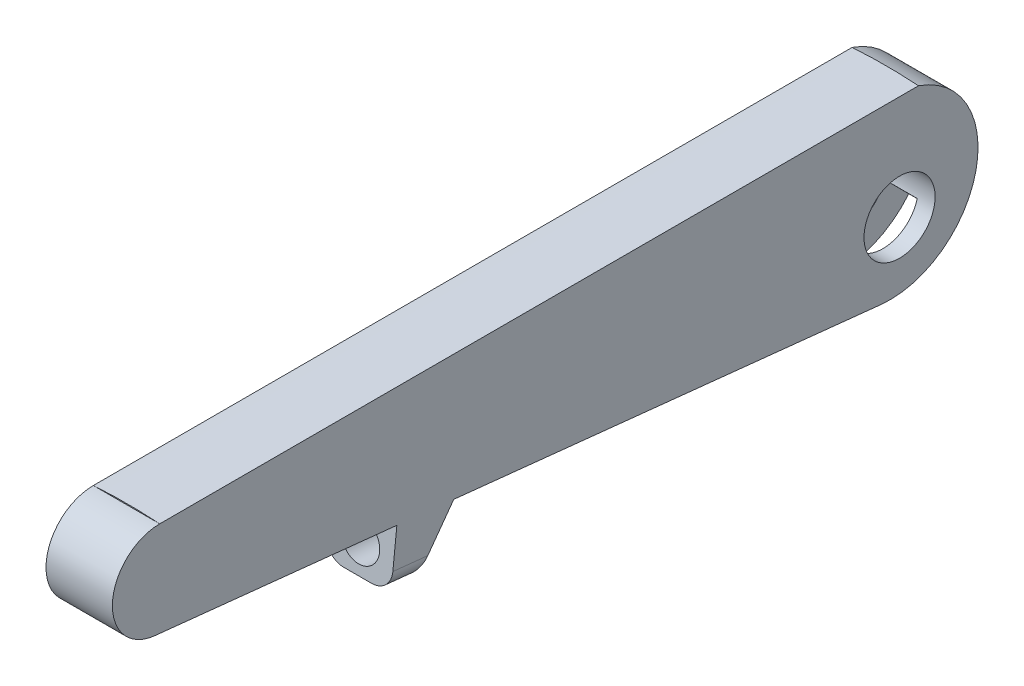
from build123d import *

# Parameters (mm, degrees)
SKETCH1_R           = 3.75
BOSS_EXTRUDE1_DEPTH = 3.5
CUT_EXTRUDE1_DEPTH  = 1.75
BOSS_EXTRUDE3_DEPTH = 80
SKETCH9_R           = 2
CUT_EXTRUDE3_DEPTH  = 7
FILLET2_R           = 2
BOSS_EXTRUDE7_DEPTH = 3.5


with BuildPart() as part:
    # Sketch1 → Boss-Extrude1 (new body, symmetric)
    with BuildSketch(Plane(origin=(0, 0, 0), x_dir=(0, 0, -1), z_dir=(1, 0, 0))):
        with BuildLine():
            Line((-80.521669114, -9.954039671), (-3.96947016, -18))
            ThreePointArc((-3.96947016, -18), (6.057083574, -10.773431066), (0, 0))
            Line((0, 0), (-80, 0))
            ThreePointArc((-80, 0), (-84.983850029, -4.729497083), (-80.521669114, -9.954039671))
        make_face()
        with Locations((-2, -11)):
            Circle(SKETCH1_R, mode=Mode.SUBTRACT)
        Polygon((-53.094727027, -18.903008846), (-49, -13.267100598), (-55, -12.636475186), (-55.630625412, -18.636475186), align=None)
    extrude(amount=BOSS_EXTRUDE1_DEPTH, both=True)

    # Sketch6 → Cut-Extrude1 (cut, symmetric)
    with BuildSketch(Plane(origin=(0, 0, 0), x_dir=(0, 0, -1), z_dir=(1, 0, 0))):
        with BuildLine():
            ThreePointArc((1.619477331, -11.980756773), (-4.659098946, -13.644180931), (-2.960378385, -7.375062296))
            Line((-2.960378385, -7.375062296), (-31.959880017, -15.058089377))
            Line((-31.959880017, -15.058089377), (-3.96947016, -18))
            ThreePointArc((-3.96947016, -18), (0.558835237, -17.340846662), (4.220806393, -14.596762087))
            Line((4.220806393, -14.596762087), (1.619477331, -11.980756773))
        make_face()
    extrude(amount=CUT_EXTRUDE1_DEPTH, both=True, mode=Mode.SUBTRACT)

    # Sketch8 → Boss-Extrude3 (add)
    with BuildSketch(Plane.XY):
        with BuildLine():
            Line((-3.5, 0), (3.5, 0))
            ThreePointArc((3.5, 0), (0, 0.120714291), (-3.5, 0))
        make_face()
    extrude(amount=BOSS_EXTRUDE3_DEPTH)

    # Sketch9 → Cut-Extrude3 (cut)
    with BuildSketch(Plane(origin=(0, 5.579502847, 53.085423559), x_dir=(1, 0, 0), z_dir=(0, 0.104528463, 0.994521895))):
        with Locations((0, -21.34936641)):
            Circle(SKETCH9_R)
    extrude(amount=-CUT_EXTRUDE3_DEPTH, mode=Mode.SUBTRACT)

    # Fillet2
    fillet2_edges = [part.edges().sort_by_distance(p)[0] for p in [
        (-3.5, -18.769742016, 54.362676219),
        (3.5, -18.769742016, 54.362676219),
    ]]
    fillet(fillet2_edges, radius=FILLET2_R)

    # Sketch10 → Boss-Extrude7 (add)
    with BuildSketch(Plane.ZY.offset(-1.75)):
        Polygon((31.959880017, -15.058089377), (30.04729926, -14.551376885), (16.886307052, -15.934652906), (16.959880017, -16.634652906), align=None)
        Polygon((31.959880017, -15.058089377), (31.886307052, -14.358089377), (30.04729926, -14.551376885), align=None)
    extrude(amount=BOSS_EXTRUDE7_DEPTH)


solid = part.part
